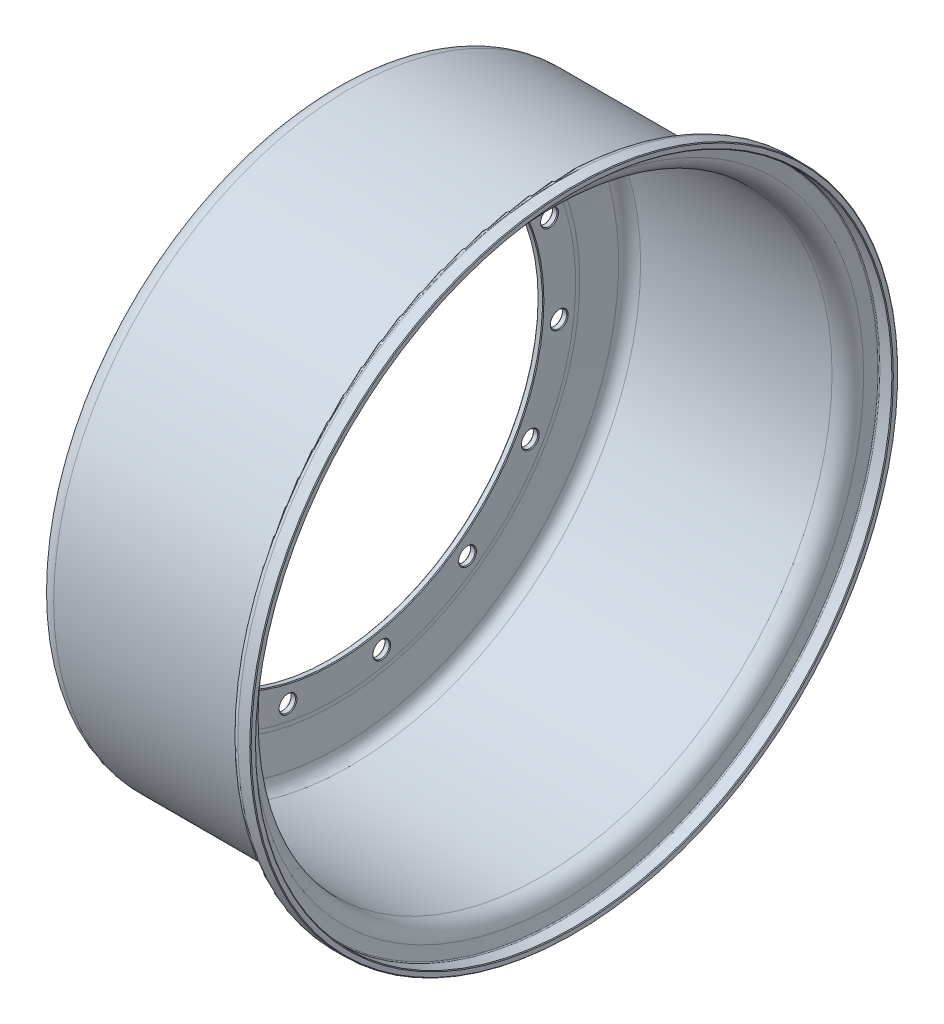
from build123d import *

# Parameters (mm, degrees)
SKETCH2_R                   = 4.49834
MOUNTING_HOLE_DEPTH         = 135.620560587
MOUNTING_HOLE_PATTERN_COUNT = 15
EDGE_CHAMFER_SIZE           = 0.39624


with BuildPart() as part:
    # Sketch1 → Outer Rim (revolve)
    with BuildSketch(Plane.XY):
        with BuildLine():
            Line((0, 114.3), (0, 132.12064))
            ThreePointArc((0, 132.12064), (0.02969217, 133.34873), (0.118699294, 134.573950146))
            Line((0.118699294, 134.573950146), (2.007086476, 154.043123701))
            ThreePointArc((2.007086476, 154.043123701), (5.085877569, 160.176614491), (11.487947569, 162.648893514))
            Line((11.487947569, 162.648893514), (116.544887569, 162.648893514))
            ThreePointArc((116.544887569, 162.648893514), (120.646987569, 164.15167281), (122.807524489, 167.948730913))
            Line((122.807524489, 167.948730913), (123.926238435, 174.619596349))
            ThreePointArc((123.926238435, 174.619596349), (125.222560587, 176.89783121), (127.683820587, 177.799498788))
            Line((127.683820587, 177.799498788), (134.620560587, 177.799498788))
            Line((134.620560587, 177.799498788), (134.620560587, 174.624498788))
            Line((134.620560587, 174.624498788), (127.683820587, 174.624498788))
            ThreePointArc((127.683820587, 174.624498788), (127.273581252, 174.474210111), (127.05751211, 174.094477147))
            Line((127.05751211, 174.094477147), (125.938798163, 167.423611711))
            ThreePointArc((125.938798163, 167.423611711), (122.698008234, 161.728051711), (116.544887569, 159.473893514))
            Line((116.544887569, 159.473893514), (11.487947569, 159.473893514))
            ThreePointArc((11.487947569, 159.473893514), (7.21982168, 157.825676906), (5.167256187, 153.736607148))
            Line((5.167256187, 153.736607148), (3.278869005, 134.267433592))
            ThreePointArc((3.278869005, 134.267433592), (3.20098243, 133.195292443), (3.175, 132.12064))
            Line((3.175, 132.12064), (3.175, 114.3))
            Line((3.175, 114.3), (0, 114.3))
        make_face()
    revolve(axis=Axis((-6.731028029, 0, 0), (1, 0, 0)))

    # Sketch2 → Mounting Hole (cut, through all)
    with BuildSketch(Plane.ZY):
        with Locations((0, 123.825)):
            Circle(SKETCH2_R)
    mounting_hole = extrude(amount=-MOUNTING_HOLE_DEPTH, mode=Mode.SUBTRACT)

    # Mounting Hole Pattern: Mounting Hole ×15 about axis
    mounting_hole_pattern_axis = Axis((0, 0, 0), (1, 0, 0))
    for i in range(1, MOUNTING_HOLE_PATTERN_COUNT):
        add(mounting_hole.rotate(mounting_hole_pattern_axis, i * 360 / MOUNTING_HOLE_PATTERN_COUNT), mode=Mode.SUBTRACT)

    # Edge Chamfer
    edge_chamfer_edges = [part.edges().sort_by_distance(p)[0] for p in [
        (3.175, 79.512179238, -95.029884987),
        (0, 79.512179238, -95.029884987),
        (3.175, 111.290126582, -54.473602903),
        (0, 111.290126582, -54.473602903),
        (3.175, -114.3, 0),
        (134.620560587, -174.624498788, 0),
        (134.620560587, -177.799498788, 0),
        (0, -114.3, 0),
        (3.175, 123.825, -4.49834),
        (0, 123.825, -4.49834),
        (3.175, 114.949406004, 46.254726755),
        (0, 114.949406004, 46.254726755),
        (3.175, 86.198015427, 89.009931043),
        (0, 86.198015427, 89.009931043),
        (3.175, 42.542204898, 116.374509624),
        (0, 42.542204898, 116.374509624),
        (3.175, -8.469539341, 123.616878261),
        (0, -8.469539341, 123.616878261),
        (3.175, -58.016823285, 109.484765624),
        (0, -58.016823285, 109.484765624),
        (3.175, -97.532471417, 76.421742372),
        (0, -97.532471417, 76.421742372),
        (3.175, -120.183869186, 30.144705594),
        (0, -120.183869186, 30.144705594),
        (3.175, -122.054384136, -21.344624637),
        (0, -122.054384136, -21.344624637),
        (3.175, -102.82058724, -69.143275359),
        (0, -102.82058724, -69.143275359),
        (3.175, -65.808176715, -104.986425624),
        (0, -65.808176715, -104.986425624),
        (3.175, -17.416934587, -122.676469127),
        (0, -17.416934587, -122.676469127),
        (3.175, 33.985853759, -119.154636637),
        (0, 33.985853759, -119.154636637),
    ]]
    chamfer(edge_chamfer_edges, length=EDGE_CHAMFER_SIZE)


solid = part.part
